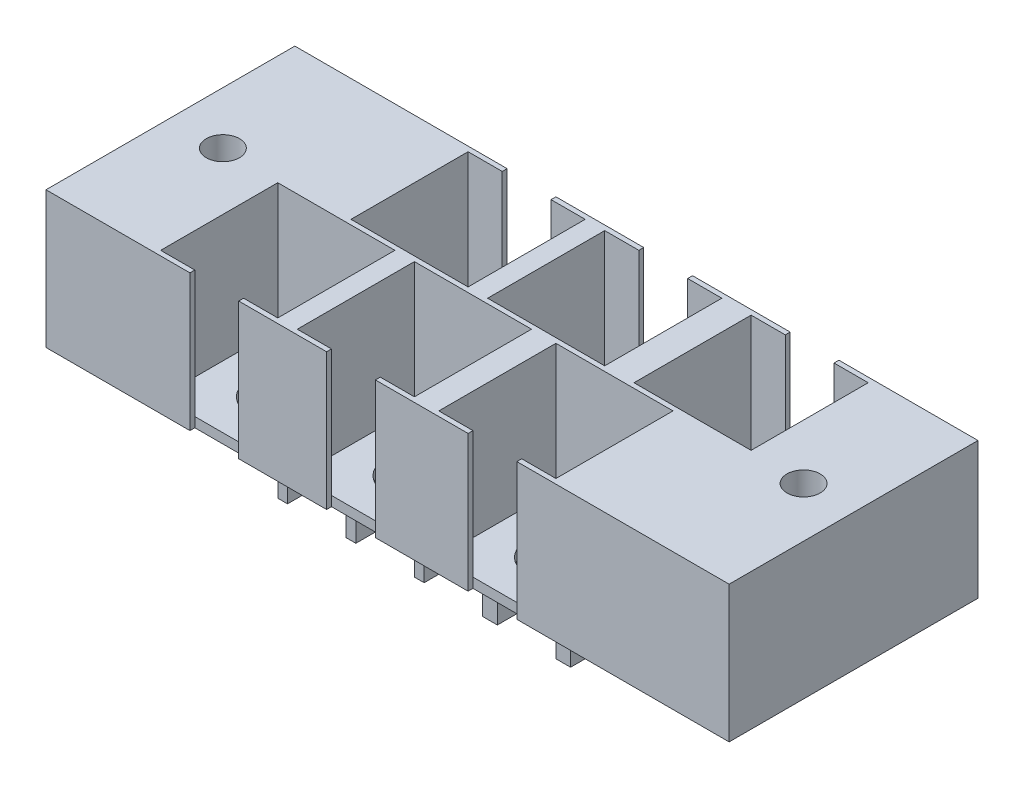
from build123d import *

# Parameters (mm, degrees)
SKETCH1_R           = 3
SKETCH1_R_2         = 1.7
BOSS_EXTRUDE1_DEPTH = 1
SKETCH1_4_R         = 1.7
BOSS_EXTRUDE2_DEPTH = 14
SKETCH1_5_W         = 1
SKETCH1_5_H         = 15.5
SKETCH1_5_W_2       = 1.5
BOSS_EXTRUDE3_DEPTH = 5


with BuildPart() as part:
    # Sketch1 → Boss-Extrude1 (new body)
    with BuildSketch(Plane(origin=(0, 0, 0), x_dir=(1, 0, 0), z_dir=(0, 1, 0))):
        Polygon((-14.735418885, -4.200712669), (-9.735418885, -4.200712669), (-9.735418885, -4.700712669), (-4.735418885, -4.700712669), (-0.735418885, -4.700712669), (-0.735418885, -4.200712669), (4.264581115, -4.200712669), (4.264581115, -4.700712669), (13.764581115, -4.700712669), (13.764581115, -4.200712669), (18.764581115, -4.200712669), (18.764581115, -4.700712669), (40.514581115, -4.700712669), (40.514581115, 20.799287331), (26.264581115, 20.799287331), (26.264581115, 20.299287331), (21.264581115, 20.299287331), (21.264581115, 20.799287331), (11.264581115, 20.799287331), (11.264581115, 20.299287331), (6.264581115, 20.299287331), (6.264581115, 20.799287331), (1.264581115, 20.799287331), (-2.735418885, 20.799287331), (-2.735418885, 20.299287331), (-7.735418885, 20.299287331), (-7.735418885, 20.799287331), (-29.485418885, 20.799287331), (-29.485418885, -4.700712669), (-14.735418885, -4.700712669), align=None)
        with Locations((-12.235418885, 1.799287331)):
            Circle(SKETCH1_R, mode=Mode.SUBTRACT)
        with Locations((-24.110418885, 8.049287331)):
            Circle(SKETCH1_R_2, mode=Mode.SUBTRACT)
        with Locations((-5.235418885, 14.299287331)):
            Circle(SKETCH1_R, mode=Mode.SUBTRACT)
        with Locations((1.764581115, 1.799287331)):
            Circle(SKETCH1_R, mode=Mode.SUBTRACT)
        with Locations((8.764581115, 14.299287331)):
            Circle(SKETCH1_R, mode=Mode.SUBTRACT)
        with Locations((16.264581115, 1.799287331)):
            Circle(SKETCH1_R, mode=Mode.SUBTRACT)
        with Locations((23.764581115, 14.299287331)):
            Circle(SKETCH1_R, mode=Mode.SUBTRACT)
        with Locations((35.389581115, 8.049287331)):
            Circle(SKETCH1_R_2, mode=Mode.SUBTRACT)
    extrude(amount=BOSS_EXTRUDE1_DEPTH)

    # Sketch1_4 → Boss-Extrude2 (add)
    with BuildSketch(Plane(origin=(0, 0, 0), x_dir=(1, 0, 0), z_dir=(0, 1, 0))):
        Polygon((-18.235418885, -4.200712669), (-18.235418885, 7.799287331), (-6.235418885, 7.799287331), (-6.235418885, -4.200712669), (-9.735418885, -4.200712669), (-9.735418885, -4.700712669), (-4.735418885, -4.700712669), (-0.735418885, -4.700712669), (-0.735418885, -4.200712669), (-4.235418885, -4.200712669), (-4.235418885, 7.799287331), (1.264581115, 7.799287331), (7.764581115, 7.799287331), (7.764581115, -4.200712669), (4.264581115, -4.200712669), (4.264581115, -4.700712669), (13.764581115, -4.700712669), (13.764581115, -4.200712669), (10.264581115, -4.200712669), (10.264581115, 7.799287331), (22.264581115, 7.799287331), (22.264581115, -4.200712669), (18.764581115, -4.200712669), (18.764581115, -4.700712669), (40.514581115, -4.700712669), (40.514581115, 20.799287331), (26.264581115, 20.799287331), (26.264581115, 20.299287331), (29.764581115, 20.299287331), (29.764581115, 8.299287331), (17.764581115, 8.299287331), (17.764581115, 20.299287331), (21.264581115, 20.299287331), (21.264581115, 20.799287331), (11.264581115, 20.799287331), (11.264581115, 20.299287331), (14.764581115, 20.299287331), (14.764581115, 8.299287331), (2.764581115, 8.299287331), (2.764581115, 20.299287331), (6.264581115, 20.299287331), (6.264581115, 20.799287331), (1.264581115, 20.799287331), (-2.735418885, 20.799287331), (-2.735418885, 20.299287331), (0.764581115, 20.299287331), (0.764581115, 8.299287331), (-11.235418885, 8.299287331), (-11.235418885, 20.299287331), (-7.735418885, 20.299287331), (-7.735418885, 20.799287331), (-29.485418885, 20.799287331), (-29.485418885, -4.700712669), (-14.735418885, -4.700712669), (-14.735418885, -4.200712669), align=None)
        with Locations((-24.110418885, 8.049287331)):
            Circle(SKETCH1_4_R, mode=Mode.SUBTRACT)
        with Locations((35.389581115, 8.049287331)):
            Circle(SKETCH1_4_R, mode=Mode.SUBTRACT)
    extrude(amount=BOSS_EXTRUDE2_DEPTH)

    # Sketch1_5 → Boss-Extrude3 (add)
    with BuildSketch(Plane(origin=(0, 0, 0), x_dir=(1, 0, 0), z_dir=(0, 1, 0))):
        with Locations((-8.735418885, 6.549287331)):
            Rectangle(SKETCH1_5_W, SKETCH1_5_H)
        with Locations((-1.735418885, 6.549287331)):
            Rectangle(SKETCH1_5_W, SKETCH1_5_H)
        with Locations((5.264581115, 6.549287331)):
            Rectangle(SKETCH1_5_W, SKETCH1_5_H)
        with Locations((12.514581115, 6.549287331)):
            Rectangle(SKETCH1_5_W_2, SKETCH1_5_H)
        with Locations((20.014581115, 6.549287331)):
            Rectangle(SKETCH1_5_W_2, SKETCH1_5_H)
    extrude(amount=-BOSS_EXTRUDE3_DEPTH)


solid = part.part
